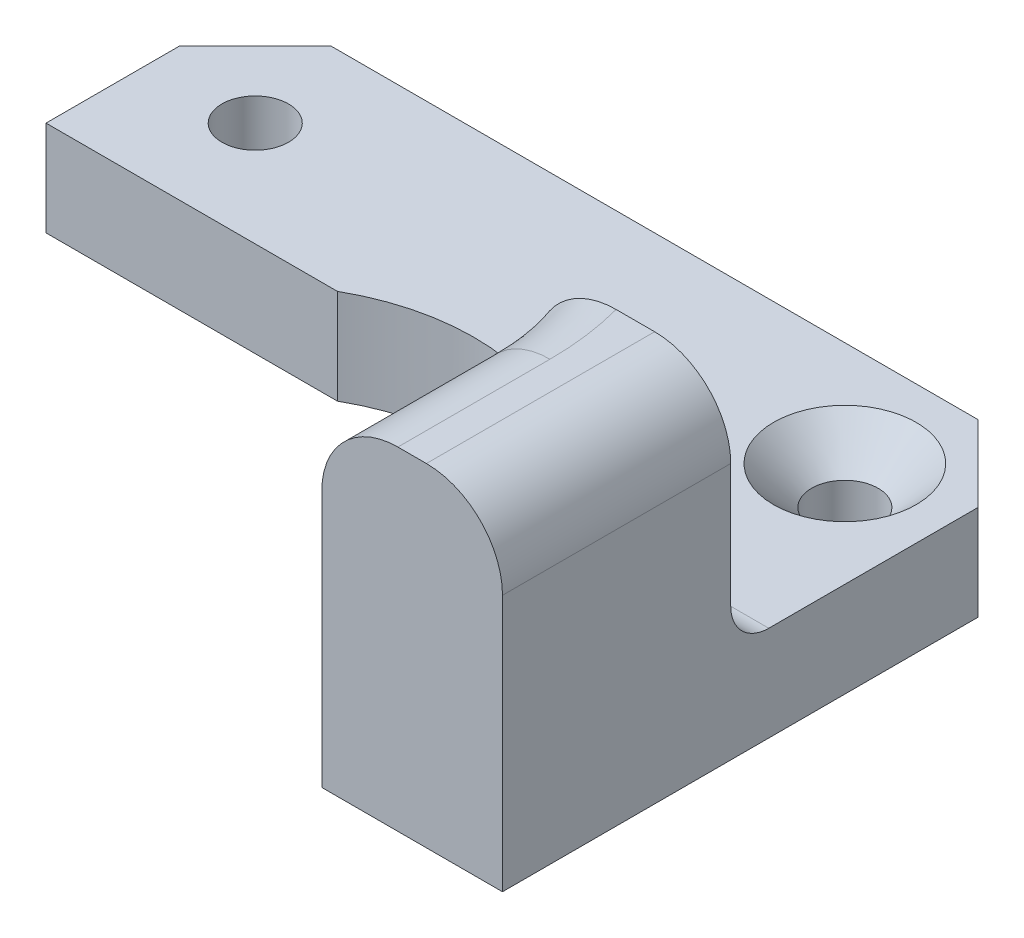
from build123d import *

# Parameters (mm, degrees)
CROQUIS1_R              = 1.75
SALIENTE_EXTRUIR1_DEPTH = 5
CHAFL_N1_SIZE           = 2
SALIENTE_EXTRUIR2_DEPTH = 17.5
CROQUIS4_R              = 2.5
SALIENTE_EXTRUIR3_DEPTH = 3
NGULO_DE_SALIDA1_ANGLE  = 20
REDONDEO1_R             = 1
CHAFL_N2_SIZE           = 4
REDONDEO2_R             = 2
REDONDEO4_R             = 4


with BuildPart() as part:
    # Croquis1 → Saliente-Extruir1 (new body)
    with BuildSketch(Plane(origin=(0, 0, 0), x_dir=(1, 0, 0), z_dir=(0, 1, 0))):
        with BuildLine():
            Line((-21, 21), (21, 21))
            Line((21, 21), (21, -8))
            Line((21, -8), (11.5, -8))
            Line((11.5, -8), (11.5, 0))
            ThreePointArc((11.5, 0), (5.785436631, 9.938748562), (-5.678908346, 10))
            Line((-5.678908346, 10), (-21, 10))
            Line((-21, 10), (-21, 21))
        make_face()
        with Locations((-15.5, 15.5)):
            Circle(CROQUIS1_R, mode=Mode.SUBTRACT)
        with Locations((15.5, 15.5)):
            Circle(CROQUIS1_R, mode=Mode.SUBTRACT)
    extrude(amount=SALIENTE_EXTRUIR1_DEPTH)

    # Chaflán1
    chafl_n1_edges = [part.edges().sort_by_distance(p)[0] for p in [
        (13.75, 5, -15.5),
    ]]
    chamfer(chafl_n1_edges, length=CHAFL_N1_SIZE)

    # Croquis3 → Saliente-Extruir2 (add)
    with BuildSketch(Plane.XZ):
        with BuildLine():
            Line((10.781929326, -4), (21, -4))
            Line((21, -4), (21, 0))
            Line((21, 0), (21, 8))
            Line((21, 8), (11.5, 8))
            Line((11.5, 8), (11.5, 0))
            ThreePointArc((11.5, 0), (11.319058867, -2.031971056), (10.781929326, -4))
        make_face()
    extrude(amount=-SALIENTE_EXTRUIR2_DEPTH)

    # Croquis4 → Saliente-Extruir3 (add)
    with BuildSketch(Plane(origin=(0, 0, -4), x_dir=(-1, 0, 0), z_dir=(0, 0, -1))):
        with Locations((-16.25, 12)):
            Circle(CROQUIS4_R)
    extrude(amount=SALIENTE_EXTRUIR3_DEPTH)

    # Ángulo de salida1
    ngulo_de_salida1_faces = [part.faces().sort_by_distance(p)[0] for p in [
        (18.75, 12, -5.5),
    ]]
    draft(ngulo_de_salida1_faces, Plane(origin=(10.781929326, 17.5, -4), x_dir=(-1, 0, 0), z_dir=(0, 0, -1)), NGULO_DE_SALIDA1_ANGLE)

    # Redondeo1
    redondeo1_edges = [part.edges().sort_by_distance(p)[0] for p in [
        (18.75, 12, -4),
        (17.658089297, 12, -7),
    ]]
    fillet(redondeo1_edges, radius=REDONDEO1_R)

    # Chaflán2
    chafl_n2_edges = [part.edges().sort_by_distance(p)[0] for p in [
        (-21, 2.5, -21),
        (21, 2.5, -21),
    ]]
    chamfer(chafl_n2_edges, length=CHAFL_N2_SIZE)

    # Redondeo2
    redondeo2_edges = [part.edges().sort_by_distance(p)[0] for p in [
        (15.890964663, 5, -4),
    ]]
    fillet(redondeo2_edges, radius=REDONDEO2_R)

    # Redondeo4
    redondeo4_edges = [part.edges().sort_by_distance(p)[0] for p in [
        (21, 17.5, 2),
        (11.319058867, 17.5, -2.031971056),
        (11.5, 17.5, 4),
    ]]
    fillet(redondeo4_edges, radius=REDONDEO4_R)


solid = part.part
